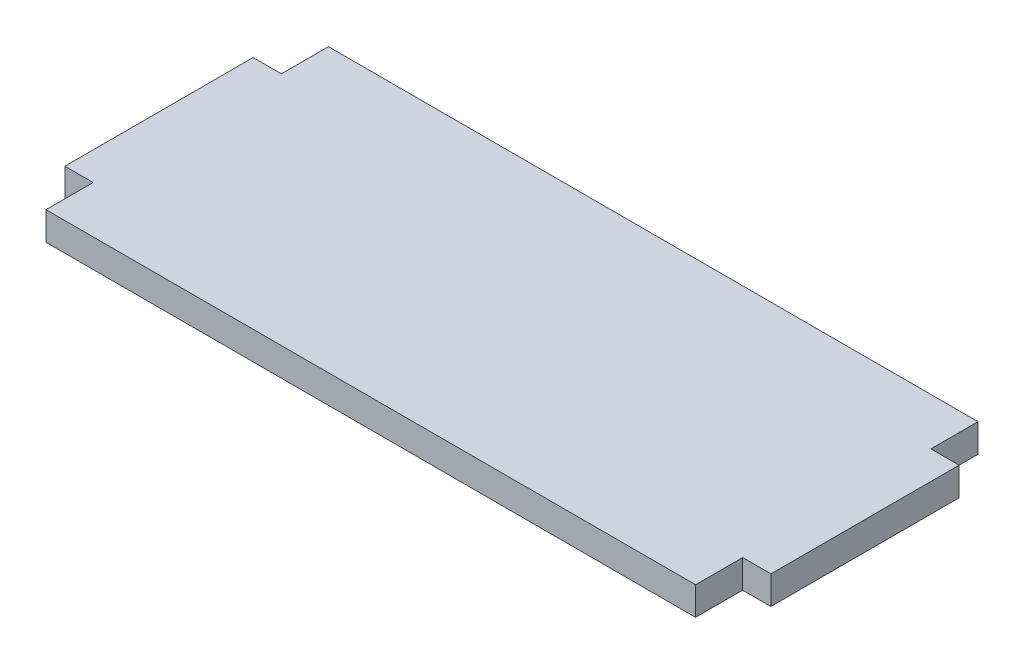
from build123d import *

# Parameters (mm, degrees)
BOSS_EXTRUDE1_DEPTH = 3


with BuildPart() as part:
    # Sketch1 → Boss-Extrude1 (new body)
    with BuildSketch(Plane(origin=(0, 0, 0), x_dir=(1, 0, 0), z_dir=(0, 1, 0))):
        Polygon((0, 25), (0, 30), (69, 30), (69, 25), (72, 25), (72, 5), (69, 5), (69, 0), (0, 0), (0, 5), (-3, 5), (-3, 25), align=None)
    extrude(amount=BOSS_EXTRUDE1_DEPTH)


solid = part.part
